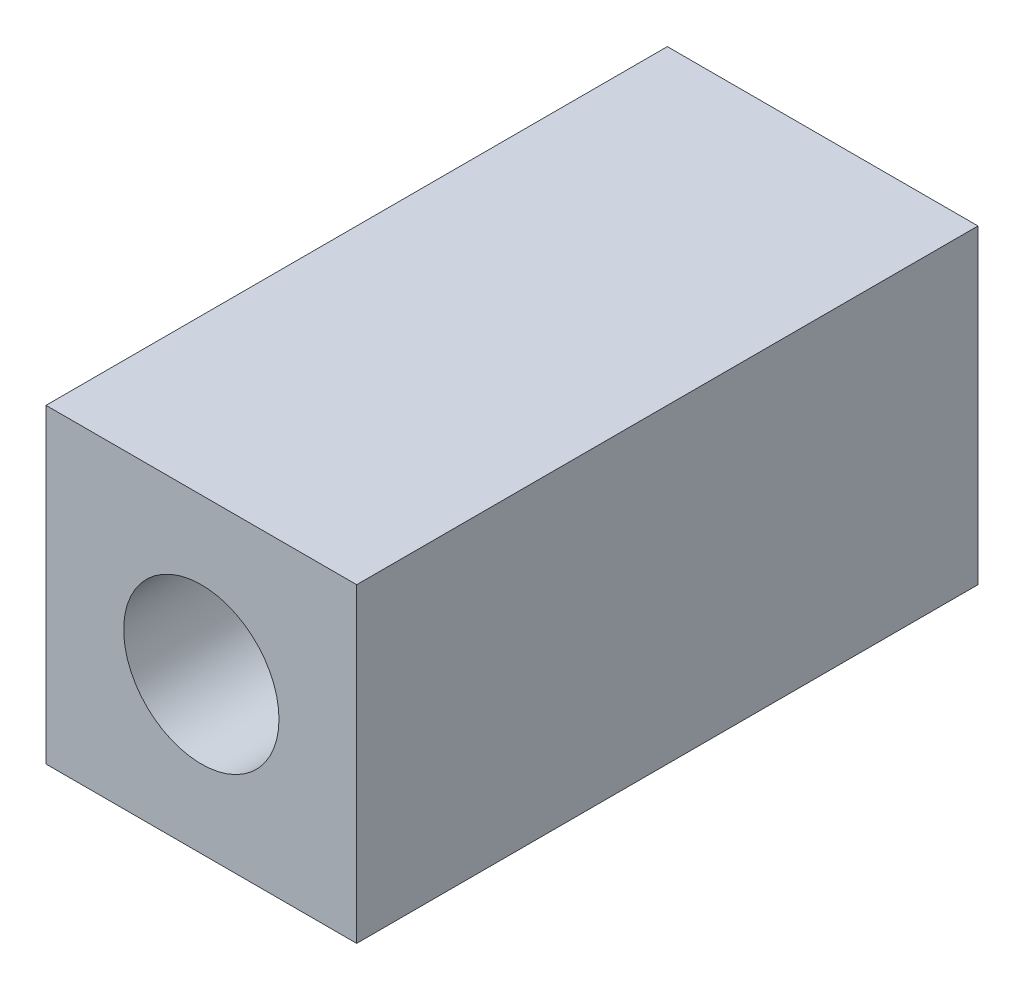
from build123d import *

# Parameters (mm, degrees)
SKETCH1_W           = 10
SKETCH1_H           = 10
SKETCH1_R           = 2.5
BOSS_EXTRUDE1_DEPTH = 20


with BuildPart() as part:
    # Sketch1 → Boss-Extrude1 (new body)
    with BuildSketch(Plane.XY):
        with Locations((5, -5)):
            Rectangle(SKETCH1_W, SKETCH1_H)
        with Locations((5, -5)):
            Circle(SKETCH1_R, mode=Mode.SUBTRACT)
    extrude(amount=BOSS_EXTRUDE1_DEPTH)


solid = part.part
